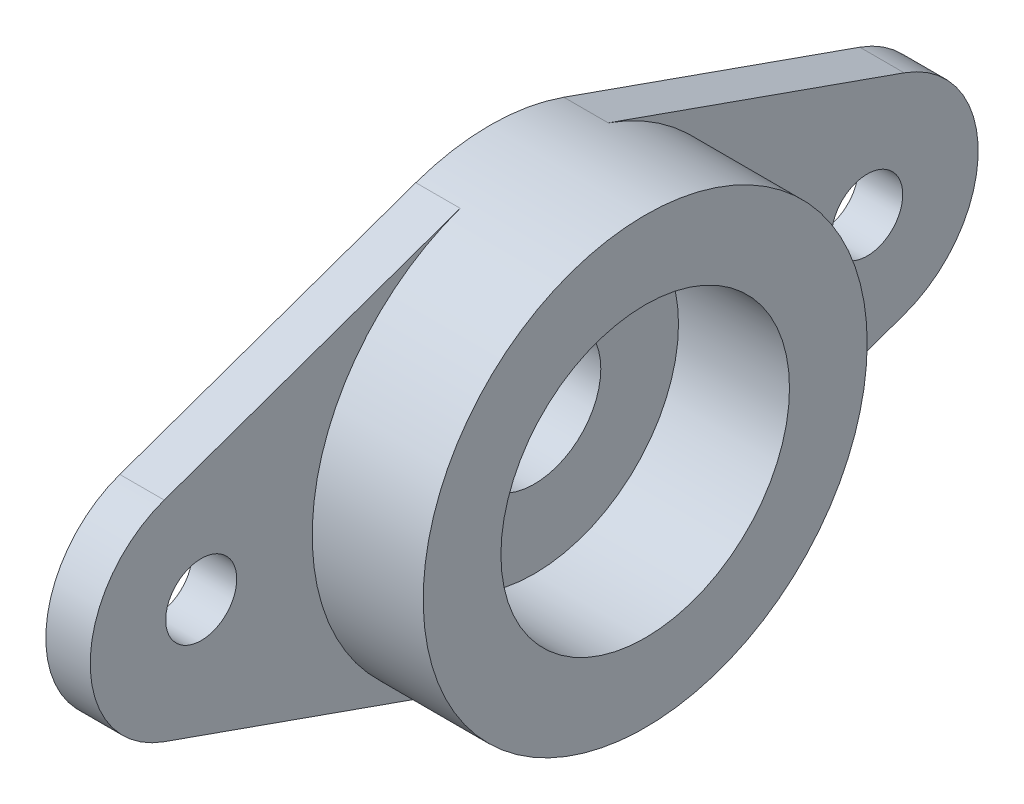
from build123d import *

# Parameters (mm, degrees)
SKETCH1_R             = 1.6
BOSS_EXTRUDE1_DEPTH   = 2
BOSS_EXTRUDE1_2_DEPTH = 2
SKETCH1_5_R           = 10
SKETCH1_5_R_2         = 6.5
BOSS_EXTRUDE2_DEPTH   = 7
SKETCH1_6_R           = 6.5
SKETCH1_6_R_2         = 3
BOSS_EXTRUDE3_DEPTH   = 2


with BuildPart() as part:
    # Sketch1 → Boss-Extrude1 (new body)
    with BuildSketch(Plane(origin=(0, 0, 0), x_dir=(0, 0, -1), z_dir=(1, 0, 0))):
        with BuildLine():
            Line((-3.333333333, 9.428090416), (-16.666666667, 4.714045208))
            ThreePointArc((-16.666666667, 4.714045208), (-20, 0), (-16.666666667, -4.714045208))
            Line((-16.666666667, -4.714045208), (-3.333333333, -9.428090416))
            ThreePointArc((-3.333333333, -9.428090416), (-10, 0), (-3.333333333, 9.428090416))
        make_face()
        with Locations((-15, 0)):
            Circle(SKETCH1_R, mode=Mode.SUBTRACT)
    extrude(amount=BOSS_EXTRUDE1_DEPTH)



with BuildPart() as body_2:
    # Sketch1 → Boss-Extrude1 2 (new body)
    with BuildSketch(Plane(origin=(0, 0, 0), x_dir=(0, 0, -1), z_dir=(1, 0, 0))):
        with BuildLine():
            Line((16.666666667, 4.714045208), (3.333333333, 9.428090416))
            ThreePointArc((3.333333333, 9.428090416), (8.164965809, 5.773502692), (10, 0))
            ThreePointArc((10, 0), (8.164965809, -5.773502692), (3.333333333, -9.428090416))
            Line((3.333333333, -9.428090416), (16.666666667, -4.714045208))
            ThreePointArc((16.666666667, -4.714045208), (20, 0), (16.666666667, 4.714045208))
        make_face()
        with Locations((15, 0)):
            Circle(SKETCH1_R, mode=Mode.SUBTRACT)
    extrude(amount=BOSS_EXTRUDE1_2_DEPTH)


with BuildPart() as part_1:
    add(part.part)

    add(body_2.part)  # Boss-Extrude2 merges body 2
    # Sketch1_5 → Boss-Extrude2 (add)
    with BuildSketch(Plane(origin=(0, 0, 0), x_dir=(0, 0, -1), z_dir=(1, 0, 0))):
        Circle(SKETCH1_5_R)
        Circle(SKETCH1_5_R_2, mode=Mode.SUBTRACT)
    extrude(amount=BOSS_EXTRUDE2_DEPTH)

    # Sketch1_6 → Boss-Extrude3 (add)
    with BuildSketch(Plane(origin=(0, 0, 0), x_dir=(0, 0, -1), z_dir=(1, 0, 0))):
        Circle(SKETCH1_6_R)
        Circle(SKETCH1_6_R_2, mode=Mode.SUBTRACT)
    extrude(amount=BOSS_EXTRUDE3_DEPTH)


solid = part_1.part
